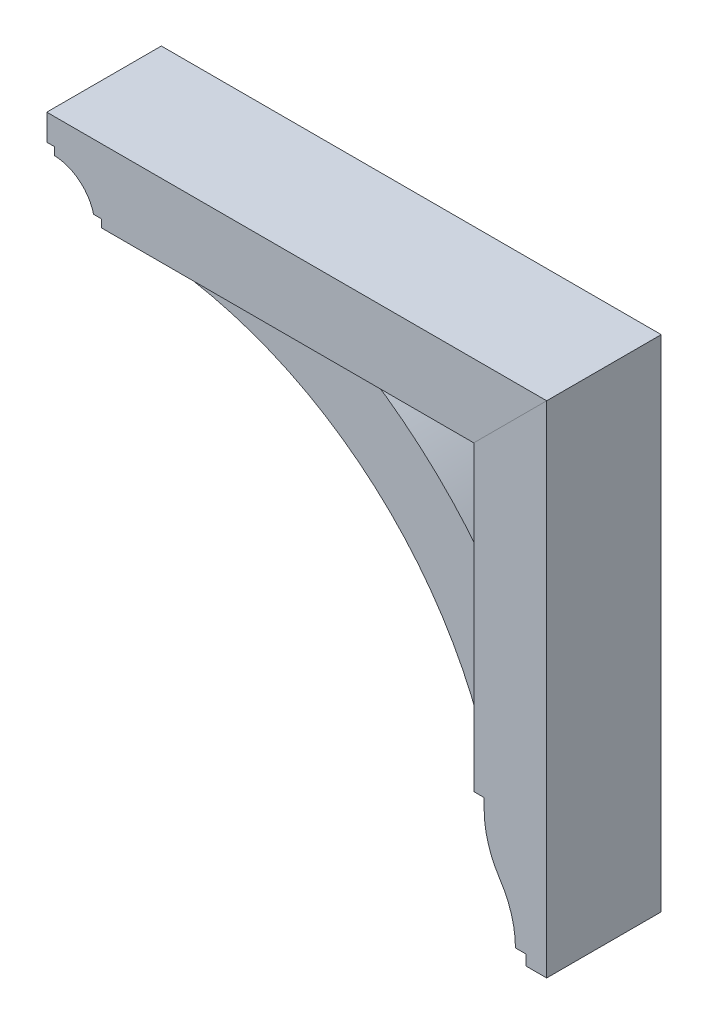
from build123d import *

# Parameters (mm, degrees)
BOSS_EXTRUDE1_DEPTH = 69.85
BOSS_EXTRUDE2_DEPTH = 44.45
BOSS_EXTRUDE3_DEPTH = 69.85


with BuildPart() as part:
    # Sketch1 → Boss-Extrude1 (new body, symmetric)
    with BuildSketch(Plane.XY):
        with BuildLine():
            Line((-276.993776984, 232.41), (-276.993776984, 241.935))
            Line((-276.993776984, 241.935), (-286.518776984, 241.935))
            Line((-286.518776984, 241.935), (-286.518776984, 273.685))
            Line((-286.518776984, 273.685), (323.081223016, 273.685))
            Line((323.081223016, 273.685), (234.181223016, 184.785))
            Line((234.181223016, 184.785), (-219.843776984, 184.785))
            Line((-219.843776984, 184.785), (-219.843776984, 194.31))
            Line((-219.843776984, 194.31), (-229.368776984, 194.31))
            ThreePointArc((-229.368776984, 194.31), (-246.816968561, 221.315385529), (-276.993776984, 232.41))
        make_face()
    extrude(amount=BOSS_EXTRUDE1_DEPTH, both=True)


with BuildPart() as body_2:
    # Sketch1_3 → Boss-Extrude2 (new body, symmetric)
    with BuildSketch(Plane.XY):
        with BuildLine():
            ThreePointArc((234.076180436, 21.58989956), (153.606360894, 113.262953084), (54.793723016, 184.785))
            Line((54.793723016, 184.785), (-184.918776984, 184.785))
            Line((-184.918776984, 184.785), (-184.918776984, 165.735))
            ThreePointArc((-184.918776984, 165.735), (59.424504699, 75.915356299), (215.131223016, -132.715))
            Line((215.131223016, -132.715), (234.181223016, -132.715))
            Line((234.181223016, -132.715), (234.181223016, 21.2725))
            ThreePointArc((234.181223016, 21.2725), (234.129070962, 21.431321978), (234.076180436, 21.58989956))
        make_face()
    extrude(amount=BOSS_EXTRUDE2_DEPTH, both=True)


with BuildPart() as body_3:
    # Sketch1_4 → Boss-Extrude3 (new body, symmetric)
    with BuildSketch(Plane.XY):
        with BuildLine():
            Line((323.081223016, -335.915), (323.081223016, 273.685))
            Line((323.081223016, 273.685), (234.181223016, 184.785))
            Line((234.181223016, 184.785), (234.181223016, -183.515))
            Line((234.181223016, -183.515), (246.881223016, -183.515))
            Line((246.881223016, -183.515), (246.881223016, -196.215))
            ThreePointArc((246.881223016, -196.215), (251.768629387, -229.515028089), (266.018608337, -260.006284404))
            ThreePointArc((266.018608337, -260.006284404), (280.138450492, -290.219081757), (284.981223016, -323.215))
            Line((284.981223016, -323.215), (297.681223016, -323.215))
            Line((297.681223016, -323.215), (297.681223016, -335.915))
            Line((297.681223016, -335.915), (323.081223016, -335.915))
        make_face()
    extrude(amount=BOSS_EXTRUDE3_DEPTH, both=True)


solid = Compound([part.part, body_2.part, body_3.part])
